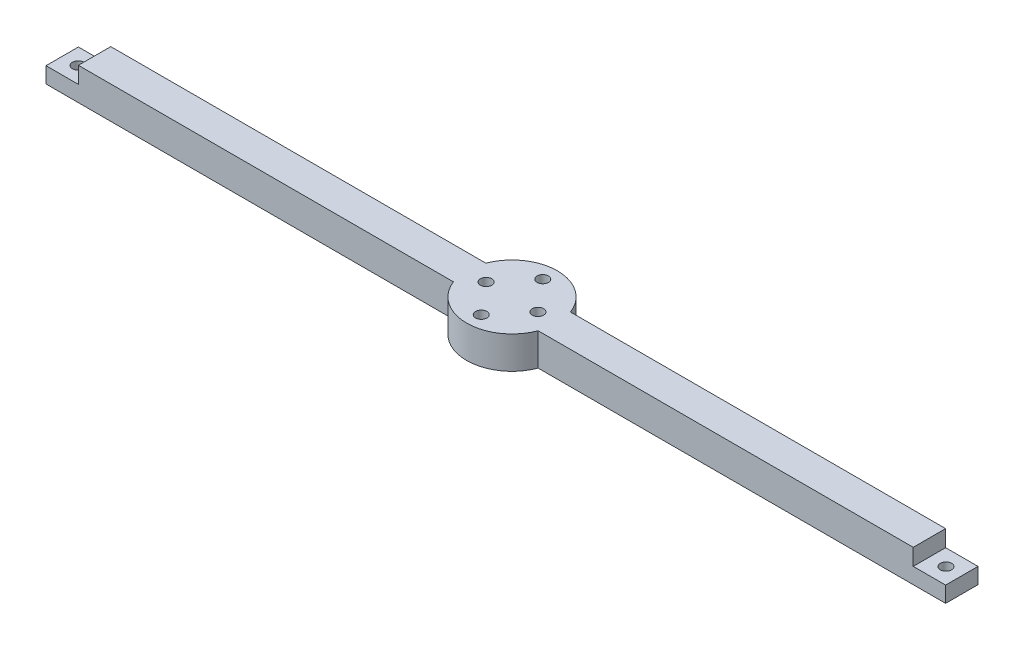
from build123d import *

# Parameters (mm, degrees)
SKETCH1_R           = 14
BOSS_EXTRUDE1_DEPTH = 10
BOSS_EXTRUDE2_DEPTH = 10
CUT_EXTRUDE2_DEPTH  = 20
SKETCH6_R           = 1.75
CUT_EXTRUDE4_DEPTH  = 10
CIRPATTERN2_COUNT   = 2
CIRPATTERN2_ANGLE   = 180
SKETCH5_R           = 1.75
CUT_EXTRUDE3_DEPTH  = 11
SKETCH8_R           = 4.75
CUT_EXTRUDE6_DEPTH  = 4


with BuildPart() as part:
    # Sketch1 → Boss-Extrude1 (new body)
    with BuildSketch(Plane(origin=(0, 0, 0), x_dir=(1, 0, 0), z_dir=(0, 1, 0))):
        Circle(SKETCH1_R)
    extrude(amount=BOSS_EXTRUDE1_DEPTH)

    # Sketch2 → Boss-Extrude2 (add)
    with BuildSketch(Plane(origin=(0, 10, 0), x_dir=(1, 0, 0), z_dir=(0, 1, 0))):
        with BuildLine():
            Line((13.076696831, -5), (149, -5))
            Line((149, -5), (149, 5))
            Line((149, 5), (13.076696831, 5))
            ThreePointArc((13.076696831, 5), (14, 0), (13.076696831, -5))
        make_face()
    boss_extrude2 = extrude(amount=-BOSS_EXTRUDE2_DEPTH)

    # Sketch4 → Cut-Extrude2 (cut, through all)
    with BuildSketch(Plane.XY.offset(5)):
        Polygon((138.9, 0), (138.9, 4.9), (128.9, 4.9), (128.9, 10), (149, 10), (149, 0), align=None)
    cut_extrude2 = extrude(amount=-CUT_EXTRUDE2_DEPTH, mode=Mode.SUBTRACT)

    # Sketch6 → Cut-Extrude4 (cut)
    with BuildSketch(Plane(origin=(0, 4.9, 0), x_dir=(1, 0, 0), z_dir=(0, 1, 0))):
        with Locations((134, 0)):
            Circle(SKETCH6_R)
    cut_extrude4 = extrude(amount=-CUT_EXTRUDE4_DEPTH, mode=Mode.SUBTRACT)

    # CirPattern2: Boss-Extrude2, Cut-Extrude2, Cut-Extrude4 ×2 about axis
    cirpattern2_axis = Axis((0, 0, 0), (0, 1, 0))
    for i in range(1, CIRPATTERN2_COUNT):
        add(boss_extrude2.rotate(cirpattern2_axis, i * CIRPATTERN2_ANGLE / (CIRPATTERN2_COUNT - 1)))
        add(cut_extrude2.rotate(cirpattern2_axis, i * CIRPATTERN2_ANGLE / (CIRPATTERN2_COUNT - 1)), mode=Mode.SUBTRACT)
        add(cut_extrude4.rotate(cirpattern2_axis, i * CIRPATTERN2_ANGLE / (CIRPATTERN2_COUNT - 1)), mode=Mode.SUBTRACT)

    # Sketch5 → Cut-Extrude3 (cut, through all)
    with BuildSketch(Plane(origin=(0, 10, 0), x_dir=(1, 0, 0), z_dir=(0, 1, 0))):
        with Locations((0, 9.5)):
            Circle(SKETCH5_R)
        with Locations((8, 0)):
            Circle(SKETCH5_R)
        with Locations((-8, 0)):
            Circle(SKETCH5_R)
        with Locations((0, -9.5)):
            Circle(SKETCH5_R)
    extrude(amount=-CUT_EXTRUDE3_DEPTH, mode=Mode.SUBTRACT)

    # Sketch8 → Cut-Extrude6 (cut)
    with BuildSketch(Plane.XZ):
        Circle(SKETCH8_R)
    extrude(amount=-CUT_EXTRUDE6_DEPTH, mode=Mode.SUBTRACT)


solid = part.part
